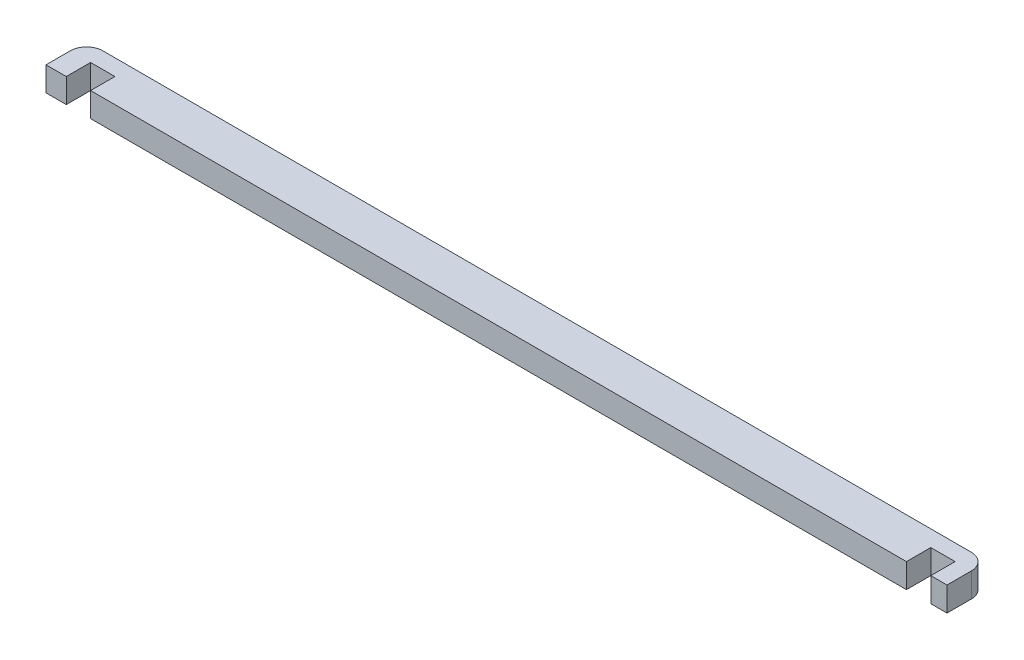
from build123d import *

# Parameters (mm, degrees)
SALIENTE_EXTRUIR1_DEPTH = 3
REDONDEO1_R             = 2


with BuildPart() as part:
    # Croquis1 → Saliente-Extruir1 (new body)
    with BuildSketch(Plane(origin=(0, 0, 0), x_dir=(1, 0, 0), z_dir=(0, 1, 0))):
        Polygon((0, 0), (2.5, 0), (2.5, 3), (5.5, 3), (5.5, 0), (106.1, 0), (106.1, 3), (109.1, 3), (109.1, 0), (111.1, 0), (111.1, 5), (0, 5), align=None)
    extrude(amount=SALIENTE_EXTRUIR1_DEPTH)

    # Redondeo1
    redondeo1_edges = [part.edges().sort_by_distance(p)[0] for p in [
        (0, 1.5, -5),
        (111.1, 1.5, -5),
    ]]
    fillet(redondeo1_edges, radius=REDONDEO1_R)


solid = part.part
